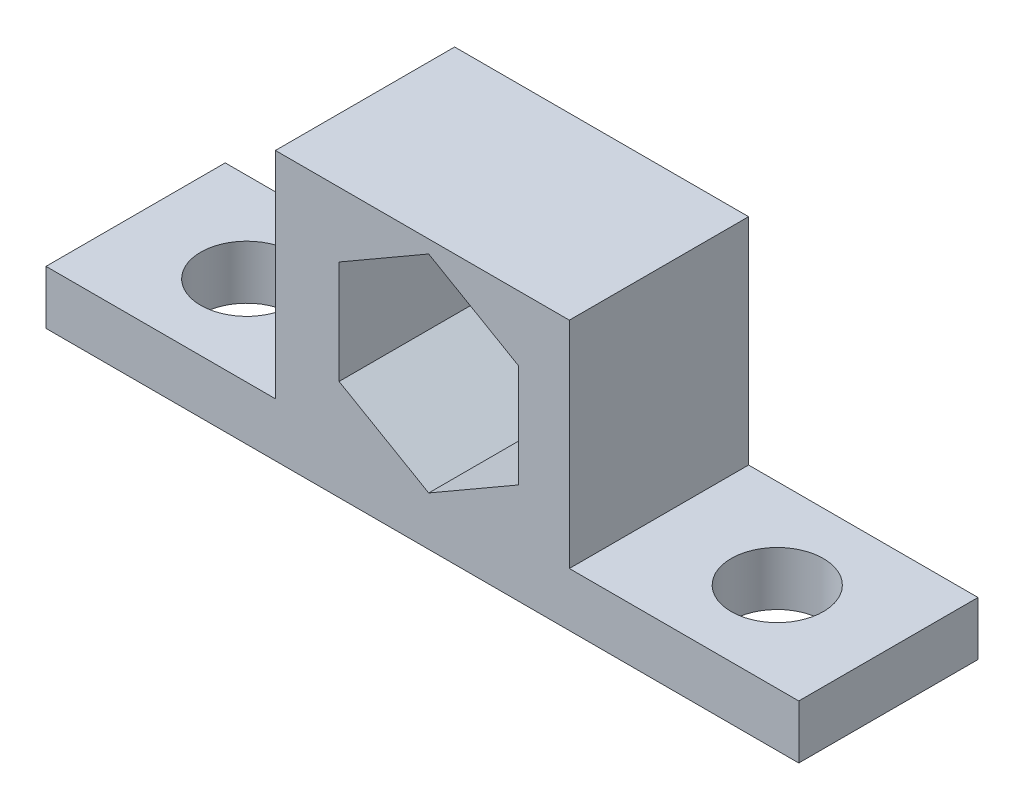
from build123d import *

# Parameters (mm, degrees)
SKETCH1_W           = 15.494
SKETCH1_H           = 12.7
SKETCH1_R           = 3.2639
SKETCH1_W_2         = 22.352
BOSS_EXTRUDE3_DEPTH = 3.81
SKETCH3_W           = 20.828
SKETCH3_H           = 12.7
BOSS_EXTRUDE4_DEPTH = 15.24
CUT_EXTRUDE2_REACH  = 14.7


with BuildPart() as part:
    # Sketch1 → Boss-Extrude3 (new body)
    with BuildSketch(Plane(origin=(0, 0, 0), x_dir=(1, 0, 0), z_dir=(0, 1, 0))):
        with Locations((-27.634045528, -3.236090754)):
            Rectangle(SKETCH1_W, SKETCH1_H)
        with Locations((-27.507045528, -3.236090754)):
            Circle(SKETCH1_R, mode=Mode.SUBTRACT)
        with Locations((-8.711045528, -3.236090754)):
            Rectangle(SKETCH1_W_2, SKETCH1_H)
        with Locations((10.211954472, -3.236090754)):
            Rectangle(SKETCH1_W, SKETCH1_H)
        with Locations((10.084954472, -3.236090754)):
            Circle(SKETCH1_R, mode=Mode.SUBTRACT)
    extrude(amount=BOSS_EXTRUDE3_DEPTH)

    # Sketch3 → Boss-Extrude4 (add)
    with BuildSketch(Plane(origin=(0, 3.81, 0), x_dir=(1, 0, 0), z_dir=(0, 1, 0))):
        with Locations((-8.711045528, -3.236090754)):
            Rectangle(SKETCH3_W, SKETCH3_H)
    extrude(amount=BOSS_EXTRUDE4_DEPTH)

    # Sketch4 → Cut-Extrude2 (cut, up to next)
    with BuildSketch(Plane.XY.offset(9.586090754), mode=Mode.PRIVATE) as cut_extrude2_sk1:
        Polygon((-8.262769146, 18.127348419), (-14.612769146, 14.461174209), (-14.612769146, 7.128825791), (-8.262769146, 3.462651581), (-1.912769146, 7.128825791), (-1.912769146, 14.461174209), align=None)
    cut_extrude2_tool1 = extrude(cut_extrude2_sk1.sketch, amount=-CUT_EXTRUDE2_REACH, mode=Mode.PRIVATE) & part.part
    add(cut_extrude2_tool1.solids().sort_by_distance((-8.262769, 10.795, 9.586091))[0], mode=Mode.SUBTRACT)


solid = part.part
